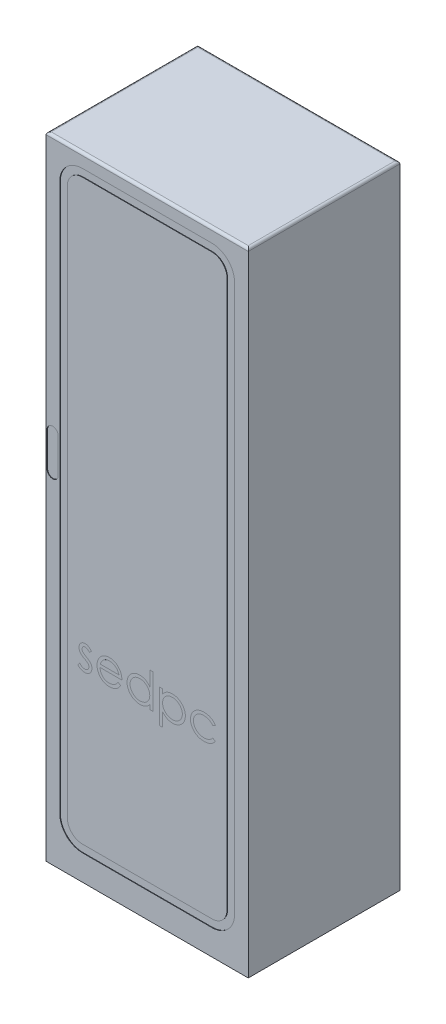
from build123d import *

# Parameters (mm, degrees)
CROQUIS1_W              = 800
CROQUIS1_H              = 600
SALIENTE_EXTRUIR1_DEPTH = 2500
CORTAR_EXTRUIR1_DEPTH   = 2
CORTAR_EXTRUIR2_DEPTH   = 2
CORTAR_EXTRUIR3_DEPTH   = 0.001
REDONDEO1_R             = 10


with BuildPart() as part:
    # Croquis1 → Saliente-Extruir1 (new body)
    with BuildSketch(Plane(origin=(0, 0, 0), x_dir=(1, 0, 0), z_dir=(0, 1, 0))):
        Rectangle(CROQUIS1_W, CROQUIS1_H)
    extrude(amount=SALIENTE_EXTRUIR1_DEPTH)

    # Croquis2 → Cortar-Extruir1 (cut)
    with BuildSketch(Plane.XY.offset(300)):
        with BuildLine():
            Line((-345.995350553, 2356.549502458), (-345.995350553, 190.849800125))
            ThreePointArc((-345.995350553, 190.849800125), (-319.63496086, 127.210189818), (-255.995350553, 100.849800125))
            Line((-255.995350553, 100.849800125), (255.995350553, 100.849800125))
            ThreePointArc((255.995350553, 100.849800125), (319.63496086, 127.210189818), (345.995350553, 190.849800125))
            Line((345.995350553, 190.849800125), (345.995350553, 2356.549502458))
            ThreePointArc((345.995350553, 2356.549502458), (319.63496086, 2420.189112765), (255.995350553, 2446.549502458))
            Line((255.995350553, 2446.549502458), (-255.995350553, 2446.549502458))
            ThreePointArc((-255.995350553, 2446.549502458), (-319.63496086, 2420.189112765), (-345.995350553, 2356.549502458))
        make_face()
        with BuildLine():
            Line((-255.995350553, 2416.549502458), (255.995350553, 2416.549502458))
            ThreePointArc((255.995350553, 2416.549502458), (298.421757424, 2398.975909329), (315.995350553, 2356.549502458))
            Line((315.995350553, 2356.549502458), (315.995350553, 190.849800125))
            ThreePointArc((315.995350553, 190.849800125), (298.421757424, 148.423393254), (255.995350553, 130.849800125))
            Line((255.995350553, 130.849800125), (-255.995350553, 130.849800125))
            ThreePointArc((-255.995350553, 130.849800125), (-298.421757424, 148.423393254), (-315.995350553, 190.849800125))
            Line((-315.995350553, 190.849800125), (-315.995350553, 2356.549502458))
            ThreePointArc((-315.995350553, 2356.549502458), (-298.421757424, 2398.975909329), (-255.995350553, 2416.549502458))
        make_face(mode=Mode.SUBTRACT)
    extrude(amount=-CORTAR_EXTRUIR1_DEPTH, mode=Mode.SUBTRACT)

    # Croquis3 → Cortar-Extruir2 (cut)
    with BuildSketch(Plane.XY.offset(300)):
        with BuildLine():
            Line((-352.039613588, 1482.116331648), (-352.039613588, 1345.934548055))
            ThreePointArc((-352.039613588, 1345.934548055), (-374.032766404, 1323.94139524), (-396.025919219, 1345.934548055))
            Line((-396.025919219, 1345.934548055), (-396.025919219, 1482.116331648))
            ThreePointArc((-396.025919219, 1482.116331648), (-374.032766404, 1504.109484464), (-352.039613588, 1482.116331648))
        make_face()
    extrude(amount=-CORTAR_EXTRUIR2_DEPTH, mode=Mode.SUBTRACT)

    # Croquis4 → Cortar-Extruir3 (cut)
    with BuildSketch(Plane.XY.offset(300)):
        with BuildLine():
            Line((-220.486111111, 809.770531321), (-228.542334402, 801.475801419))
            add(Edge.make_bspline(
                [(-228.542334402, 801.475801419), (-229.237451648, 802.281387605), (-230.577555867, 803.834462934), (-232.702971964, 805.910953246), (-234.82053079, 807.654819688), (-236.901244874, 809.127122331), (-238.997435402, 810.240229956), (-241.084503438, 811.052684559), (-243.164609924, 811.555461142), (-244.555034469, 811.620262843), (-245.237797142, 811.652083471)],
                knots=[0, 0, 0, 0, 0.003191111, 0.006152086, 0.008900508, 0.011414588, 0.013785626, 0.016000302, 0.018121685, 0.020168427, 0.020168427, 0.020168427, 0.020168427], degree=3))
            add(Edge.make_bspline(
                [(-245.237797142, 811.652083471), (-246.074613365, 811.611455831), (-247.721349262, 811.531506387), (-250.080896562, 810.73346899), (-252.27129221, 809.50849584), (-254.167106633, 807.770992831), (-255.773039777, 805.776629098), (-256.945283077, 803.546708485), (-257.662152101, 801.1485235), (-257.753045247, 799.484299713), (-257.799145299, 798.640222827)],
                knots=[0, 0, 0, 0, 0.002502461, 0.004924489, 0.007393043, 0.009983346, 0.01258663, 0.015040346, 0.017497495, 0.020026337, 0.020026337, 0.020026337, 0.020026337], degree=3))
            add(Edge.make_bspline(
                [(-257.799145299, 798.640222827), (-257.75715924, 797.876255682), (-257.673305481, 796.350475005), (-257.02142207, 794.099701107), (-255.983269937, 791.905283294), (-255.012997713, 790.561090108), (-254.51305422, 789.868479705)],
                knots=[0, 0, 0, 0, 0.002288903, 0.004571353, 0.006977672, 0.009535508, 0.009535508, 0.009535508, 0.009535508], degree=3))
            add(Edge.make_bspline(
                [(-254.51305422, 789.868479705), (-254.212053116, 789.498645714), (-253.571410203, 788.711500675), (-252.369124072, 787.619003835), (-251.007559232, 786.411662801), (-249.370168728, 785.204526403), (-247.527495948, 783.933327266), (-245.439582527, 782.648127597), (-243.172689035, 781.250960347), (-241.549761077, 780.364816503), (-240.706171541, 779.904203529)],
                knots=[0, 0, 0, 0, 0.001428584, 0.003040561, 0.004862956, 0.006887619, 0.009136905, 0.011577995, 0.014241286, 0.017124147, 0.017124147, 0.017124147, 0.017124147], degree=3))
            add(Edge.make_bspline(
                [(-240.706171541, 779.904203529), (-239.677563121, 779.3279825), (-237.690630354, 778.214913211), (-234.867421592, 776.487195251), (-232.305232841, 774.769995583), (-229.982354927, 773.081678981), (-227.943482985, 771.375008092), (-226.126757334, 769.715399421), (-224.577491746, 768.052708304), (-223.709887969, 766.891069781), (-223.295188969, 766.335827461)],
                knots=[0, 0, 0, 0, 0.003536831, 0.006831992, 0.009926343, 0.012788545, 0.015441929, 0.017898506, 0.020167841, 0.022245742, 0.022245742, 0.022245742, 0.022245742], degree=3))
            add(Edge.make_bspline(
                [(-223.295188969, 766.335827461), (-222.606874391, 765.214519966), (-221.237000633, 762.982909942), (-219.798488776, 759.308284857), (-218.964662912, 755.410953366), (-218.848918278, 752.74500338), (-218.790064103, 751.389413198)],
                knots=[0, 0, 0, 0, 0.003941132, 0.007843585, 0.011773028, 0.015838106, 0.015838106, 0.015838106, 0.015838106], degree=3))
            add(Edge.make_bspline(
                [(-218.790064103, 751.389413198), (-218.817260768, 750.434299635), (-218.870854767, 748.55214402), (-219.243466226, 745.780262064), (-219.884323962, 743.129342776), (-220.757212876, 740.570622194), (-221.935907923, 738.15312656), (-223.317327637, 735.815863577), (-224.975694837, 733.609392383), (-226.86902957, 731.536610258), (-228.942058658, 729.643488257), (-231.153451387, 727.97948762), (-233.505930997, 726.597064755), (-235.982688074, 725.453106766), (-238.589349999, 724.543383921), (-241.326324326, 723.913579912), (-244.18491118, 723.536633287), (-246.128835476, 723.484303384), (-247.119349292, 723.457639026)],
                knots=[0, 0, 0, 0, 0.002865145, 0.005646081, 0.008371408, 0.011036544, 0.013739099, 0.016425103, 0.019170584, 0.022003189, 0.024835794, 0.027581275, 0.03029006, 0.033005319, 0.035754251, 0.038556946, 0.041416694, 0.044387732, 0.044387732, 0.044387732, 0.044387732], degree=3))
            add(Edge.make_bspline(
                [(-247.119349292, 723.457639026), (-248.456144316, 723.495160735), (-251.111159709, 723.569682791), (-255.037943737, 724.269167841), (-258.875186698, 725.357565173), (-262.593850275, 726.858732922), (-266.110771842, 728.754310462), (-269.328518099, 731.024525934), (-272.258266829, 733.594385955), (-273.925832533, 735.564129901), (-274.759615385, 736.549001873)],
                knots=[0, 0, 0, 0, 0.004007223, 0.007958766, 0.011926538, 0.015956915, 0.019964839, 0.023883544, 0.027750291, 0.031617038, 0.031617038, 0.031617038, 0.031617038], degree=3))
            Line((-274.759615385, 736.549001873), (-266.888897236, 745.506250137))
            add(Edge.make_bspline(
                [(-266.888897236, 745.506250137), (-266.141547102, 744.699090883), (-264.692695867, 743.134290623), (-262.375655827, 741.050721794), (-260.017862988, 739.304423748), (-257.642861442, 737.843794677), (-255.215494781, 736.718355332), (-252.74936591, 735.927682288), (-250.249490953, 735.419523832), (-248.570439986, 735.359868518), (-247.728866186, 735.329968086)],
                knots=[0, 0, 0, 0, 0.003298889, 0.006395395, 0.00933172, 0.01209047, 0.0147465, 0.017336125, 0.019846431, 0.022369017, 0.022369017, 0.022369017, 0.022369017], degree=3))
            add(Edge.make_bspline(
                [(-247.728866186, 735.329968086), (-246.58292077, 735.381782002), (-244.343935657, 735.483017702), (-241.13704359, 736.402145883), (-238.176030031, 737.843367276), (-235.604909531, 739.887640093), (-233.416345704, 742.267210844), (-231.831560541, 744.94759571), (-230.838383671, 747.850129936), (-230.721740269, 749.862184231), (-230.662393162, 750.885899243)],
                knots=[0, 0, 0, 0, 0.003431001, 0.0067036, 0.009927227, 0.01325093, 0.016497135, 0.019574075, 0.022532321, 0.025596453, 0.025596453, 0.025596453, 0.025596453], degree=3))
            add(Edge.make_bspline(
                [(-230.662393162, 750.885899243), (-230.703452502, 751.72914971), (-230.784518672, 753.394034879), (-231.42115425, 755.803645984), (-232.427056702, 758.089240819), (-233.417530018, 759.426885224), (-233.921983507, 760.108154852)],
                knots=[0, 0, 0, 0, 0.002526481, 0.004988198, 0.007431445, 0.009967359, 0.009967359, 0.009967359, 0.009967359], degree=3))
            add(Edge.make_bspline(
                [(-233.921983507, 760.108154852), (-234.225210915, 760.449670028), (-234.885749726, 761.193613426), (-236.097361523, 762.268013728), (-237.548104529, 763.426060928), (-239.254295211, 764.64811801), (-241.219373088, 765.918065293), (-243.451302664, 767.229240215), (-245.919508073, 768.643919136), (-247.664648007, 769.582043013), (-248.57688969, 770.072431027)],
                knots=[0, 0, 0, 0, 0.001369091, 0.002982374, 0.004848936, 0.006937625, 0.009275104, 0.011865677, 0.01470237, 0.017809292, 0.017809292, 0.017809292, 0.017809292], degree=3))
            add(Edge.make_bspline(
                [(-248.57688969, 770.072431027), (-249.561390668, 770.621975587), (-251.470652255, 771.687717869), (-254.174969501, 773.34764114), (-256.614705807, 775.035957773), (-258.84856681, 776.657960923), (-260.820128631, 778.299169221), (-262.521624296, 779.961404619), (-264.020043466, 781.577630283), (-264.849603374, 782.722795958), (-265.245851696, 783.269796812)],
                knots=[0, 0, 0, 0, 0.003382349, 0.006559455, 0.009514376, 0.012281134, 0.014839518, 0.017200911, 0.019414952, 0.021439615, 0.021439615, 0.021439615, 0.021439615], degree=3))
            add(Edge.make_bspline(
                [(-265.245851696, 783.269796812), (-265.931145195, 784.371431666), (-267.301971675, 786.57508635), (-268.633022056, 790.253190679), (-269.547952314, 794.125369929), (-269.629685514, 796.797164722), (-269.671474359, 798.163209606)],
                knots=[0, 0, 0, 0, 0.003881973, 0.007765303, 0.011674498, 0.015764206, 0.015764206, 0.015764206, 0.015764206], degree=3))
            add(Edge.make_bspline(
                [(-269.671474359, 798.163209606), (-269.651283048, 799.056193397), (-269.611765791, 800.803889194), (-269.296380508, 803.371814842), (-268.722169996, 805.811581371), (-268.00193929, 808.159828872), (-267.000944777, 810.371068736), (-265.80480491, 812.474788623), (-264.399208789, 814.468080762), (-262.779834403, 816.320282481), (-260.999315372, 818.00262904), (-259.075614254, 819.4691248), (-257.051995627, 820.720466187), (-254.919891673, 821.769923149), (-252.658820225, 822.563725408), (-250.284585979, 823.110180142), (-247.801994709, 823.475123819), (-246.104839055, 823.50774635), (-245.237797142, 823.524412531)],
                knots=[0, 0, 0, 0, 0.002678672, 0.005242541, 0.007743318, 0.010190586, 0.012598801, 0.015008183, 0.017441926, 0.019902502, 0.022377165, 0.024778225, 0.0271463, 0.029504865, 0.031893609, 0.034316942, 0.036805472, 0.039404706, 0.039404706, 0.039404706, 0.039404706], degree=3))
            add(Edge.make_bspline(
                [(-245.237797142, 823.524412531), (-244.210001886, 823.482671082), (-242.135131002, 823.398405157), (-239.02232222, 822.729172209), (-235.914097683, 821.628010238), (-232.802471062, 820.107176419), (-229.71023691, 818.139172479), (-226.610195005, 815.760594795), (-223.465129575, 812.987091895), (-221.501304645, 810.866674744), (-220.486111111, 809.770531321)],
                knots=[0, 0, 0, 0, 0.003081387, 0.006220578, 0.009506028, 0.012954994, 0.016587142, 0.02048284, 0.024668698, 0.029148263, 0.029148263, 0.029148263, 0.029148263], degree=3))
        make_face()
        with BuildLine():
            Line((-115.702206864, 755.682532189), (-105.15491453, 750.143878676))
            add(Edge.make_bspline(
                [(-105.15491453, 750.143878676), (-105.995404886, 748.653014667), (-107.630666278, 745.752383697), (-110.442837403, 741.7673104), (-113.390752052, 738.182292569), (-116.607479414, 735.093106231), (-119.996779779, 732.399973525), (-123.577448576, 730.043752174), (-127.368127103, 728.035998578), (-131.368994677, 726.344459578), (-135.61365033, 725.043862628), (-140.112380266, 724.125220945), (-144.873802859, 723.557377159), (-148.137482872, 723.491414993), (-149.808652177, 723.457639026)],
                knots=[0, 0, 0, 0, 0.005131366, 0.009983607, 0.014611761, 0.019034764, 0.023334912, 0.027583303, 0.031874867, 0.03618635, 0.040595518, 0.04516918, 0.049945344, 0.054957417, 0.054957417, 0.054957417, 0.054957417], degree=3))
            add(Edge.make_bspline(
                [(-149.808652177, 723.457639026), (-151.666101923, 723.500999522), (-155.289448271, 723.585583289), (-160.563718475, 724.31479251), (-165.529547682, 725.504372734), (-170.186656708, 727.166165523), (-174.523640659, 729.336781642), (-178.549119398, 731.981083484), (-182.284262191, 735.085487158), (-185.611367717, 738.676882492), (-188.606597807, 742.520218378), (-191.249627312, 746.525098536), (-193.459179021, 750.681446603), (-195.256554466, 754.962802721), (-196.708166922, 759.34218203), (-197.719884594, 763.859430953), (-198.303092331, 768.502323572), (-198.392462742, 771.643205011), (-198.4375, 773.226018433)],
                knots=[0, 0, 0, 0, 0.005570263, 0.010865969, 0.015937312, 0.020866306, 0.025666159, 0.030451138, 0.03528627, 0.040198136, 0.045107, 0.049891979, 0.054574817, 0.059206384, 0.06380722, 0.068397664, 0.073071796, 0.077820162, 0.077820162, 0.077820162, 0.077820162], degree=3))
            add(Edge.make_bspline(
                [(-198.4375, 773.226018433), (-198.397466979, 774.711269464), (-198.318126819, 777.654840867), (-197.818034558, 782.011604009), (-196.931744909, 786.24601278), (-195.715556474, 790.361585664), (-194.1450183, 794.3514318), (-192.223681443, 798.217979443), (-189.948552877, 801.957114194), (-188.191996459, 804.315804069), (-187.307191506, 805.503913065)],
                knots=[0, 0, 0, 0, 0.004455986, 0.008831177, 0.013134589, 0.017419275, 0.021690829, 0.025981084, 0.030357879, 0.034800212, 0.034800212, 0.034800212, 0.034800212], degree=3))
            add(Edge.make_bspline(
                [(-187.307191506, 805.503913065), (-186.108716592, 806.93526619), (-183.749731408, 809.752630805), (-179.7599525, 813.454466333), (-175.439677222, 816.555525693), (-170.843047306, 819.126033517), (-165.916638912, 821.079174341), (-160.726674638, 822.534669264), (-155.21405873, 823.350266705), (-151.445438775, 823.465467559), (-149.517144097, 823.524412531)],
                knots=[0, 0, 0, 0, 0.005596739, 0.011016188, 0.016274898, 0.021518094, 0.026773798, 0.032135926, 0.037656544, 0.043441054, 0.043441054, 0.043441054, 0.043441054], degree=3))
            add(Edge.make_bspline(
                [(-149.517144097, 823.524412531), (-147.534749492, 823.473232706), (-143.645743172, 823.372829558), (-137.974886216, 822.442012789), (-132.609109133, 820.965919209), (-127.550559119, 818.881237247), (-122.798723311, 816.191575616), (-118.384488699, 812.86002387), (-114.232363076, 808.988864025), (-111.816770958, 806.011802241), (-110.587565104, 804.496885153)],
                knots=[0, 0, 0, 0, 0.005943318, 0.011659435, 0.017188951, 0.022607363, 0.028030957, 0.03352192, 0.039164834, 0.045011415, 0.045011415, 0.045011415, 0.045011415], degree=3))
            add(Edge.make_bspline(
                [(-110.587565104, 804.496885153), (-109.751219519, 803.35526169), (-108.084095316, 801.079613752), (-105.995886475, 797.368977754), (-104.183211129, 793.486761837), (-102.734316472, 789.370211917), (-101.56109723, 785.068102786), (-100.71228295, 780.54967922), (-100.214502724, 775.816286738), (-100.116656128, 772.591146099), (-100.066773504, 770.946955266)],
                knots=[0, 0, 0, 0, 0.004242187, 0.008456138, 0.012748357, 0.017081936, 0.021530588, 0.026114832, 0.030858759, 0.035792453, 0.035792453, 0.035792453, 0.035792453], degree=3))
            Line((-100.066773504, 770.946955266), (-186.56517094, 770.946955266))
            add(Edge.make_bspline(
                [(-186.56517094, 770.946955266), (-186.506977483, 769.673157956), (-186.392542396, 767.168286922), (-185.859023592, 763.503022204), (-185.018072917, 760.011529807), (-183.836176799, 756.719998161), (-182.404900207, 753.585436793), (-180.651630555, 750.631097896), (-178.559927177, 747.87043804), (-176.226842706, 745.278763494), (-173.62987809, 742.970812105), (-170.897762347, 740.905105086), (-167.991368671, 739.173762591), (-164.933613729, 737.768451282), (-161.729442088, 736.668301835), (-158.377844237, 735.917345518), (-154.885415434, 735.414368562), (-152.504704654, 735.35844074), (-151.292693309, 735.329968086)],
                knots=[0, 0, 0, 0, 0.003823552, 0.00751886, 0.011092531, 0.014579368, 0.017994263, 0.021416553, 0.024861649, 0.028369869, 0.031860329, 0.035268328, 0.03863152, 0.041987187, 0.045347769, 0.048774161, 0.052278376, 0.055912457, 0.055912457, 0.055912457, 0.055912457], degree=3))
            add(Edge.make_bspline(
                [(-151.292693309, 735.329968086), (-150.107694575, 735.35295118), (-147.75642977, 735.398554047), (-144.254825935, 735.841992347), (-140.809968799, 736.559023598), (-137.436116157, 737.53760358), (-134.201741922, 738.731133407), (-131.206448809, 740.171330705), (-128.451750183, 741.764490775), (-125.877091029, 743.586701707), (-123.379764792, 745.81707068), (-120.902414859, 748.60032561), (-118.246124688, 751.892026809), (-116.583422819, 754.369496922), (-115.702206864, 755.682532189)],
                knots=[0, 0, 0, 0, 0.00355357, 0.007050964, 0.010569579, 0.014100547, 0.017580629, 0.020899575, 0.024058503, 0.027117587, 0.030346112, 0.034078955, 0.038283896, 0.043025454, 0.043025454, 0.043025454, 0.043025454], degree=3))
        make_face()
        with BuildLine():
            add(Edge.make_bspline(
                [(-111.939102564, 782.819284325), (-112.373647599, 784.394041755), (-113.210006911, 787.42494289), (-114.957631401, 791.622024165), (-116.925811659, 795.352191852), (-119.254966387, 798.586898221), (-121.893947981, 801.459650051), (-124.942143872, 803.970114431), (-128.360405323, 806.215952611), (-132.131063319, 808.11159768), (-136.124071266, 809.725172697), (-140.304721975, 810.807133918), (-144.570477647, 811.548327927), (-147.455731923, 811.617350478), (-148.907627204, 811.652083471)],
                knots=[0, 0, 0, 0, 0.004896401, 0.009423995, 0.013609601, 0.017522029, 0.021347692, 0.025280262, 0.029337558, 0.033592391, 0.037922971, 0.042229891, 0.046525627, 0.050876915, 0.050876915, 0.050876915, 0.050876915], degree=3))
            add(Edge.make_bspline(
                [(-148.907627204, 811.652083471), (-150.092561338, 811.628963743), (-152.434927002, 811.583260901), (-155.885889996, 811.149717322), (-159.199973854, 810.433080328), (-162.401632046, 809.45166679), (-165.448908916, 808.143544017), (-168.404484977, 806.609594678), (-171.193208287, 804.737040766), (-172.937239396, 803.309845956), (-173.818317642, 802.588832269)],
                knots=[0, 0, 0, 0, 0.00355357, 0.00702466, 0.010413647, 0.013716153, 0.017053247, 0.020348728, 0.02369297, 0.027107453, 0.027107453, 0.027107453, 0.027107453], degree=3))
            add(Edge.make_bspline(
                [(-173.818317642, 802.588832269), (-174.449283954, 802.018303077), (-175.726205992, 800.863691042), (-177.432410227, 798.874432342), (-179.066041188, 796.729358415), (-180.552759611, 794.346402812), (-181.91640648, 791.752700749), (-183.192453236, 788.970129417), (-184.340987264, 785.9775736), (-184.987179519, 783.892186761), (-185.319636418, 782.819284325)],
                knots=[0, 0, 0, 0, 0.002549586, 0.00515974, 0.007846919, 0.010633532, 0.013573561, 0.016633105, 0.01981242, 0.023181455, 0.023181455, 0.023181455, 0.023181455], degree=3))
            Line((-185.319636418, 782.819284325), (-111.939102564, 782.819284325))
        make_face(mode=Mode.SUBTRACT)
        with BuildLine():
            Line((22.048611111, 860.837446719), (22.048611111, 725.153686035))
            Line((22.048611111, 725.153686035), (10.176282051, 725.153686035))
            Line((10.176282051, 725.153686035), (10.176282051, 741.87564951))
            add(Edge.make_bspline(
                [(10.176282051, 741.87564951), (8.837536096, 740.36224819), (6.22495653, 737.408826486), (1.861557131, 733.550363418), (-2.763668641, 730.361063765), (-7.628272148, 727.785159213), (-12.727860513, 725.850221369), (-18.051129288, 724.474911188), (-23.600249933, 723.590679918), (-27.389550248, 723.502383854), (-29.309812366, 723.457639026)],
                knots=[0, 0, 0, 0, 0.006057549, 0.011821382, 0.017422762, 0.022875735, 0.028294471, 0.03374519, 0.039348388, 0.04510515, 0.04510515, 0.04510515, 0.04510515], degree=3))
            add(Edge.make_bspline(
                [(-29.309812366, 723.457639026), (-31.017053479, 723.503992978), (-34.383808544, 723.595405024), (-39.336395686, 724.304575428), (-44.102382496, 725.443441187), (-48.686272593, 727.027195045), (-53.058404281, 729.128017768), (-57.256211506, 731.643118512), (-61.257947187, 734.638233221), (-65.002615475, 738.062245007), (-68.45096787, 741.781341249), (-71.477093353, 745.74803305), (-74.000200836, 749.945167751), (-76.110066982, 754.319605413), (-77.735226429, 758.905020526), (-78.868158438, 763.685556338), (-79.576502704, 768.655560487), (-79.667876962, 772.03994127), (-79.714209402, 773.756033123)],
                knots=[0, 0, 0, 0, 0.0051202, 0.010097261, 0.014975844, 0.019803344, 0.024615982, 0.029501686, 0.034462634, 0.039584137, 0.044703994, 0.049659702, 0.054522713, 0.059370682, 0.064206975, 0.069085558, 0.074088866, 0.079235538, 0.079235538, 0.079235538, 0.079235538], degree=3))
            add(Edge.make_bspline(
                [(-79.714209402, 773.756033123), (-79.666850067, 775.436655252), (-79.573223216, 778.759154539), (-78.875735442, 783.645581516), (-77.702837198, 788.3520753), (-76.056832242, 792.86348357), (-73.946139301, 797.185265228), (-71.378619345, 801.320476888), (-68.354086954, 805.280510661), (-64.867165617, 808.972250484), (-61.089869245, 812.382374892), (-57.048973761, 815.346050122), (-52.844998544, 817.905585776), (-48.412735944, 819.933559434), (-43.817788828, 821.574320231), (-39.019250848, 822.709494918), (-34.037087012, 823.378411525), (-30.654559484, 823.475277908), (-28.938802083, 823.524412531)],
                knots=[0, 0, 0, 0, 0.005040785, 0.00996536, 0.014773035, 0.019568423, 0.024344808, 0.029176453, 0.034148219, 0.039266704, 0.044390126, 0.049393645, 0.054279348, 0.059128693, 0.063989971, 0.068894325, 0.073894053, 0.079040724, 0.079040724, 0.079040724, 0.079040724], degree=3))
            add(Edge.make_bspline(
                [(-28.938802083, 823.524412531), (-26.965131077, 823.465180032), (-23.091034228, 823.348913219), (-17.425227015, 822.377273752), (-12.065992927, 820.745819739), (-6.982478222, 818.512309999), (-2.20498919, 815.60942446), (2.301493952, 812.103640568), (6.458601693, 807.89573951), (8.918161652, 804.735421109), (10.176282051, 803.118846959)],
                knots=[0, 0, 0, 0, 0.005918214, 0.011616796, 0.017183338, 0.022688607, 0.028228782, 0.033911629, 0.039776919, 0.045918918, 0.045918918, 0.045918918, 0.045918918], degree=3))
            Line((10.176282051, 803.118846959), (10.176282051, 860.837446719))
            Line((10.176282051, 860.837446719), (22.048611111, 860.837446719))
        make_face()
        with BuildLine():
            add(Edge.make_bspline(
                [(-28.779797676, 811.652083471), (-30.515250328, 811.590335854), (-33.940757827, 811.46845588), (-38.969504333, 810.516957699), (-43.781648259, 808.933819757), (-48.353121899, 806.768700279), (-52.61171223, 804.046185532), (-56.41769324, 800.753204675), (-59.802194155, 796.979603247), (-62.648667237, 792.742410384), (-64.969081853, 788.19996468), (-66.600692882, 783.451660026), (-67.67676265, 778.583138553), (-67.786697802, 775.281037037), (-67.841880342, 773.623529451)],
                knots=[0, 0, 0, 0, 0.00520387, 0.010271611, 0.015291455, 0.020365013, 0.025407749, 0.030406352, 0.035417514, 0.040569982, 0.045678029, 0.050673118, 0.05560026, 0.06056609, 0.06056609, 0.06056609, 0.06056609], degree=3))
            add(Edge.make_bspline(
                [(-67.841880342, 773.623529451), (-67.771391815, 771.975927185), (-67.630691052, 768.687180699), (-66.619578496, 763.812021993), (-64.923226137, 759.06259838), (-62.608421981, 754.479221541), (-59.709850153, 750.223810605), (-56.350070726, 746.378276211), (-52.496592831, 743.071378082), (-48.228201939, 740.303172175), (-43.66950782, 738.066969749), (-38.875487196, 736.511006589), (-33.936259206, 735.506429762), (-30.577852539, 735.389087929), (-28.885800614, 735.329968086)],
                knots=[0, 0, 0, 0, 0.004941161, 0.009862955, 0.014866824, 0.020034128, 0.025223402, 0.030274208, 0.035310184, 0.040403981, 0.045500466, 0.050495134, 0.055489732, 0.060561352, 0.060561352, 0.060561352, 0.060561352], degree=3))
            add(Edge.make_bspline(
                [(-28.885800614, 735.329968086), (-27.168031016, 735.39271077), (-23.751557656, 735.517499746), (-18.70789221, 736.473071381), (-13.813290937, 738.051832509), (-9.134428436, 740.240281644), (-4.775753241, 742.952538846), (-0.86377989, 746.12780687), (2.444115343, 749.820754603), (5.248419336, 753.87932887), (7.447311574, 758.32856207), (9.049025716, 763.065896065), (9.996003702, 768.091495772), (10.115358365, 771.525935868), (10.176282051, 773.279019902)],
                knots=[0, 0, 0, 0, 0.005150968, 0.010244765, 0.015340216, 0.020544963, 0.025699612, 0.0307079, 0.035604803, 0.040522385, 0.04546447, 0.050442378, 0.055484068, 0.060740841, 0.060740841, 0.060740841, 0.060740841], degree=3))
            add(Edge.make_bspline(
                [(10.176282051, 773.279019902), (10.140009325, 774.614705758), (10.068613122, 777.243758209), (9.523171952, 781.103935212), (8.655530388, 784.798037357), (7.432922176, 788.32994852), (5.826852795, 791.680141067), (3.889809263, 794.872670099), (1.587728276, 797.890931362), (-1.042331963, 800.693362914), (-3.921195274, 803.249482172), (-6.967477018, 805.531106747), (-10.217268942, 807.405444288), (-13.615918849, 808.956706633), (-17.169323455, 810.191144739), (-20.906397478, 811.014667688), (-24.78741871, 811.580132204), (-27.434992828, 811.627847191), (-28.779797676, 811.652083471)],
                knots=[0, 0, 0, 0, 0.004005908, 0.007884895, 0.011670885, 0.015375305, 0.019073653, 0.022795945, 0.026559143, 0.030440302, 0.034307048, 0.038096746, 0.041837482, 0.045537444, 0.049291954, 0.05309774, 0.057002981, 0.061034229, 0.061034229, 0.061034229, 0.061034229], degree=3))
        make_face(mode=Mode.SUBTRACT)
        with BuildLine():
            Line((49.185363248, 821.828365522), (61.057692308, 821.828365522))
            Line((61.057692308, 821.828365522), (61.057692308, 803.940369729))
            add(Edge.make_bspline(
                [(61.057692308, 803.940369729), (62.318525782, 805.563313834), (64.76870332, 808.717180917), (68.991638712, 812.798950659), (73.448991311, 816.241380291), (78.255465534, 818.939470079), (83.33636096, 820.973768624), (88.67082653, 822.477337117), (94.304136988, 823.363369044), (98.155580289, 823.470021119), (100.119774973, 823.524412531)],
                knots=[0, 0, 0, 0, 0.006158727, 0.011968254, 0.01756537, 0.023012028, 0.028444938, 0.03394893, 0.039608559, 0.04549894, 0.04549894, 0.04549894, 0.04549894], degree=3))
            add(Edge.make_bspline(
                [(100.119774973, 823.524412531), (101.835469499, 823.474777495), (105.22662986, 823.37667124), (110.218305477, 822.712451618), (115.025232176, 821.574074553), (119.620215169, 819.933623287), (124.052479835, 817.905574275), (128.256410394, 815.346031561), (132.297488241, 812.382464231), (136.074082293, 808.971903768), (139.563610173, 805.281787746), (142.581605709, 801.312194703), (145.184799712, 797.193668371), (147.28900437, 792.862360124), (148.937296073, 788.352377329), (150.109577043, 783.645498759), (150.80723202, 778.75917601), (150.900835996, 775.436662465), (150.948183761, 773.756033123)],
                knots=[0, 0, 0, 0, 0.005146672, 0.010172667, 0.015077022, 0.0199383, 0.024787645, 0.029673348, 0.034676866, 0.039800288, 0.044918773, 0.04989054, 0.05473619, 0.059512576, 0.064307964, 0.069115638, 0.074040214, 0.079080999, 0.079080999, 0.079080999, 0.079080999], degree=3))
            add(Edge.make_bspline(
                [(150.948183761, 773.756033123), (150.901863324, 772.039933961), (150.810512739, 768.655538762), (150.101996146, 763.685639551), (148.96969763, 758.90471798), (147.342200827, 754.320726173), (145.239085047, 749.936820305), (142.680013867, 745.756161883), (139.660495616, 741.780090365), (136.209530372, 738.062584915), (132.465565229, 734.6381466), (128.463648215, 731.643136231), (124.265885256, 729.128030677), (119.893752748, 727.027127145), (115.309822364, 725.443702331), (110.535481213, 724.301541414), (105.573328652, 723.597201844), (102.197957728, 723.504516698), (100.490785256, 723.457639026)],
                knots=[0, 0, 0, 0, 0.005146672, 0.01014998, 0.015028563, 0.019864856, 0.024712825, 0.029589608, 0.034545316, 0.039665173, 0.044786676, 0.049747624, 0.054633328, 0.059445966, 0.064273466, 0.069152049, 0.074155357, 0.079275557, 0.079275557, 0.079275557, 0.079275557], degree=3))
            add(Edge.make_bspline(
                [(100.490785256, 723.457639026), (98.569624055, 723.506579675), (94.774767442, 723.603251804), (89.226165019, 724.582943792), (83.88623639, 726.047107729), (78.814142717, 728.190194691), (73.969704565, 730.921281153), (69.380325002, 734.251637153), (65.021626306, 738.174297671), (62.39814054, 741.150172865), (61.057692308, 742.670671545)],
                knots=[0, 0, 0, 0, 0.005758043, 0.011373823, 0.016852301, 0.022340001, 0.027845844, 0.033501997, 0.039318773, 0.045395825, 0.045395825, 0.045395825, 0.045395825], degree=3))
            Line((61.057692308, 742.670671545), (61.057692308, 689.536698855))
            Line((61.057692308, 689.536698855), (49.185363248, 689.536698855))
            Line((49.185363248, 689.536698855), (49.185363248, 821.828365522))
        make_face()
        with BuildLine():
            add(Edge.make_bspline(
                [(100.013772035, 811.652083471), (98.668949286, 811.627883235), (96.021339927, 811.580239208), (92.140574508, 811.014259596), (88.402562804, 810.192624735), (84.84497714, 808.948633268), (81.43371872, 807.421654317), (78.195061302, 805.513554489), (75.131278242, 803.258850697), (72.250077987, 800.700732639), (69.647209454, 797.881986986), (67.342955926, 794.873757296), (65.407441716, 791.679853209), (63.800966545, 788.330025519), (62.578467468, 784.79801623), (61.710795917, 781.103941048), (61.165362939, 777.243756679), (61.093965607, 774.614705242), (61.057692308, 773.279019902)],
                knots=[0, 0, 0, 0, 0.004031249, 0.00793649, 0.011742276, 0.015496785, 0.019220869, 0.022938725, 0.026749766, 0.030616513, 0.034479626, 0.038242824, 0.041965116, 0.045663464, 0.049367884, 0.053153873, 0.05703286, 0.061038769, 0.061038769, 0.061038769, 0.061038769], degree=3))
            add(Edge.make_bspline(
                [(61.057692308, 773.279019902), (61.117822881, 771.525659696), (61.235623765, 768.090678556), (62.193315948, 763.0717549), (63.751910749, 758.322421492), (65.964156772, 753.882673963), (68.759199013, 749.801179897), (72.126897187, 746.146505188), (76.036779324, 742.941622729), (80.42384282, 740.242069389), (85.126703115, 738.050258549), (90.032301577, 736.481120237), (95.073176539, 735.514550892), (98.481324339, 735.39182886), (100.199277177, 735.329968086)],
                knots=[0, 0, 0, 0, 0.005256773, 0.010298464, 0.01526797, 0.020210055, 0.025127637, 0.030060264, 0.035068552, 0.040245699, 0.045474476, 0.050595156, 0.055662898, 0.060813866, 0.060813866, 0.060813866, 0.060813866], degree=3))
            add(Edge.make_bspline(
                [(100.199277177, 735.329968086), (101.882623168, 735.388795427), (105.223762336, 735.505557122), (110.143429428, 736.516196951), (114.924474392, 738.060041628), (119.466998768, 740.311251054), (123.731457979, 743.070101461), (127.582338129, 746.379662237), (130.946587539, 750.215740449), (133.814079531, 754.48719279), (136.124704124, 759.067333779), (137.860757836, 763.80645174), (138.862718789, 768.687841244), (139.004716451, 771.976147655), (139.075854701, 773.623529451)],
                knots=[0, 0, 0, 0, 0.005045172, 0.010013759, 0.015008427, 0.020081086, 0.025174883, 0.030210859, 0.035261666, 0.040436099, 0.045603403, 0.050616176, 0.05553797, 0.060479131, 0.060479131, 0.060479131, 0.060479131], degree=3))
            add(Edge.make_bspline(
                [(139.075854701, 773.623529451), (139.020869226, 775.281143623), (138.911326667, 778.583457482), (137.83231661, 783.450388637), (136.210799597, 788.208654399), (133.846216382, 792.726246607), (131.041585067, 796.988838421), (127.649362266, 800.751738014), (123.846309602, 804.046581895), (119.586927512, 806.768592922), (115.015667383, 808.933848237), (110.203466692, 810.516950065), (105.174735292, 811.468457857), (101.749225732, 811.590336519), (100.013772035, 811.652083471)],
                knots=[0, 0, 0, 0, 0.00496583, 0.009892972, 0.014888062, 0.020008124, 0.025145782, 0.030156944, 0.035155548, 0.040198283, 0.045271841, 0.050291685, 0.055359427, 0.060563296, 0.060563296, 0.060563296, 0.060563296], degree=3))
        make_face(mode=Mode.SUBTRACT)
        with BuildLine():
            Line((269.671474359, 800.866284526), (259.733698918, 794.691613385))
            add(Edge.make_bspline(
                [(259.733698918, 794.691613385), (258.64399865, 796.045841367), (256.499108681, 798.711409226), (252.774560164, 802.151368014), (248.805378734, 805.10589608), (244.52373824, 807.513746191), (239.935644011, 809.374199821), (235.059189812, 810.69069866), (229.895071026, 811.511067362), (226.354749515, 811.604307922), (224.540723491, 811.652083471)],
                knots=[0, 0, 0, 0, 0.005208524, 0.010252095, 0.015160171, 0.020025059, 0.02494621, 0.029973603, 0.035149665, 0.040588776, 0.040588776, 0.040588776, 0.040588776], degree=3))
            add(Edge.make_bspline(
                [(224.540723491, 811.652083471), (223.090846251, 811.612137351), (220.235352448, 811.533464556), (216.04336391, 811.041698884), (212.050334491, 810.148087261), (208.231236268, 808.970655267), (204.613232353, 807.392593713), (201.186843472, 805.472105907), (197.921677629, 803.240154979), (194.91235437, 800.654399245), (192.159591305, 797.842306747), (189.77460259, 794.827806952), (187.698117317, 791.701192017), (186.068814801, 788.384385094), (184.735497345, 784.953266414), (183.858338576, 781.343070083), (183.273809911, 777.600047178), (183.206933502, 775.048014694), (183.173076923, 773.756033123)],
                knots=[0, 0, 0, 0, 0.004350078, 0.00856736, 0.012637531, 0.016610344, 0.020538982, 0.024454012, 0.028379342, 0.03238341, 0.036337706, 0.040166031, 0.043900002, 0.047573964, 0.051230873, 0.05492019, 0.058698009, 0.062571561, 0.062571561, 0.062571561, 0.062571561], degree=3))
            add(Edge.make_bspline(
                [(183.173076923, 773.756033123), (183.24032842, 772.06386354), (183.373925259, 768.702324889), (184.42097448, 763.740325209), (186.134885114, 758.942911913), (188.480524112, 754.344146016), (191.446772942, 750.088355028), (194.930676377, 746.271420889), (198.934165536, 742.967303155), (203.421964942, 740.228014261), (208.288701078, 738.025873283), (213.481719918, 736.456994927), (218.95858662, 735.510074893), (222.708365453, 735.39078776), (224.620225694, 735.329968086)],
                knots=[0, 0, 0, 0, 0.005073351, 0.010078343, 0.015141024, 0.020320341, 0.025517797, 0.030657163, 0.035777363, 0.041036073, 0.04638535, 0.05175899, 0.057270251, 0.063003237, 0.063003237, 0.063003237, 0.063003237], degree=3))
            add(Edge.make_bspline(
                [(224.620225694, 735.329968086), (226.372341294, 735.379085986), (229.815713401, 735.475615694), (234.849119712, 736.289359248), (239.641098485, 737.621484685), (244.191479403, 739.479148839), (248.491947584, 741.880337684), (252.514716993, 744.842127771), (256.339833708, 748.279314747), (258.588677763, 750.937166638), (259.733698918, 752.290438172)],
                knots=[0, 0, 0, 0, 0.005253833, 0.010325177, 0.015250394, 0.020147009, 0.025035012, 0.029985829, 0.035107331, 0.040419985, 0.040419985, 0.040419985, 0.040419985], degree=3))
            Line((259.733698918, 752.290438172), (269.671474359, 745.771257482))
            add(Edge.make_bspline(
                [(269.671474359, 745.771257482), (269.082296329, 744.906042507), (267.905895824, 743.178484313), (265.939375458, 740.742650141), (263.818179438, 738.462634173), (261.550583216, 736.341492642), (259.166195642, 734.32846632), (256.583563345, 732.519790736), (253.885961959, 730.813801901), (251.041722962, 729.278732029), (248.080253127, 727.898879995), (245.00571959, 726.712368482), (241.831482622, 725.692962694), (238.55381007, 724.882682027), (235.166240104, 724.235933072), (231.677533684, 723.806790186), (228.088892355, 723.486444739), (225.663337827, 723.467324175), (224.434720553, 723.457639026)],
                knots=[0, 0, 0, 0, 0.003139303, 0.006268185, 0.009380866, 0.012474195, 0.015578855, 0.018733445, 0.021924556, 0.025149925, 0.028422309, 0.031719602, 0.035030073, 0.038417298, 0.04184246, 0.045369448, 0.048958904, 0.052643364, 0.052643364, 0.052643364, 0.052643364], degree=3))
            add(Edge.make_bspline(
                [(224.434720553, 723.457639026), (222.559547271, 723.491327281), (218.884194028, 723.557356504), (213.504742103, 724.283391139), (208.363749325, 725.377920088), (203.462972104, 726.948930269), (198.801647476, 728.971283381), (194.384121876, 731.441619141), (190.225022379, 734.380451676), (186.365477911, 737.735473018), (182.820762536, 741.373140102), (179.777064269, 745.298419738), (177.137079338, 749.366995059), (175.017103752, 753.668724168), (173.329556235, 758.14643319), (172.176546194, 762.835992854), (171.430809084, 767.698741743), (171.344502774, 771.014835797), (171.300747863, 772.696003743)],
                knots=[0, 0, 0, 0, 0.005622154, 0.011019463, 0.016253811, 0.021374491, 0.026430579, 0.031473035, 0.036531553, 0.041679657, 0.046796221, 0.051742283, 0.056557329, 0.061321642, 0.066101335, 0.070883304, 0.075785438, 0.080826224, 0.080826224, 0.080826224, 0.080826224], degree=3))
            add(Edge.make_bspline(
                [(171.300747863, 772.696003743), (171.317417223, 773.836676716), (171.350575331, 776.105663529), (171.730892243, 779.473244918), (172.222203571, 782.795978626), (173.05472399, 786.031746589), (174.016319294, 789.229625112), (175.243817073, 792.351069715), (176.683732298, 795.410585623), (178.318552925, 798.400291474), (180.158871564, 801.271003234), (182.195453893, 803.983120917), (184.351593982, 806.569225148), (186.728161312, 808.940033959), (189.22430299, 811.190360236), (191.910639333, 813.260086959), (194.771762298, 815.155297035), (197.764703359, 816.911034821), (200.887720722, 818.474322992), (204.121937131, 819.821174542), (207.447864129, 820.972209405), (210.87082196, 821.88346915), (214.368091004, 822.647639615), (217.967230862, 823.128343925), (221.654472596, 823.468003646), (224.151232978, 823.505453231), (225.41524773, 823.524412531)],
                knots=[0, 0, 0, 0, 0.003420238, 0.006803418, 0.010158143, 0.013487546, 0.016815367, 0.020171662, 0.023538507, 0.026954225, 0.03038717, 0.03375808, 0.03712409, 0.040478397, 0.043819171, 0.047201001, 0.050640793, 0.054108746, 0.057604935, 0.06110915, 0.064612262, 0.06815445, 0.07173038, 0.075343238, 0.079040542, 0.082831629, 0.082831629, 0.082831629, 0.082831629], degree=3))
            add(Edge.make_bspline(
                [(225.41524773, 823.524412531), (226.998216099, 823.489567243), (230.15624042, 823.420050842), (234.840904034, 822.834994642), (239.456567612, 821.952933664), (243.922246821, 820.646163015), (248.183796623, 819.063816504), (252.172785365, 817.286847836), (255.795313101, 815.223301814), (259.118766619, 812.966023681), (262.149361471, 810.419941827), (264.918206875, 807.55461933), (267.482081711, 804.384968484), (268.93565384, 802.048858998), (269.671474359, 800.866284526)],
                knots=[0, 0, 0, 0, 0.004747257, 0.009470786, 0.014143114, 0.018831647, 0.023409759, 0.027774262, 0.031915929, 0.035899952, 0.0398122, 0.043766496, 0.047838996, 0.052014019, 0.052014019, 0.052014019, 0.052014019], degree=3))
        make_face()
    extrude(amount=-CORTAR_EXTRUIR3_DEPTH, mode=Mode.SUBTRACT)

    # Redondeo1
    redondeo1_edges = [part.edges().sort_by_distance(p)[0] for p in [
        (-400, 2500, 0),
        (0, 2500, 300),
        (400, 2500, 0),
        (0, 2500, -300),
    ]]
    fillet(redondeo1_edges, radius=REDONDEO1_R)


solid = part.part
